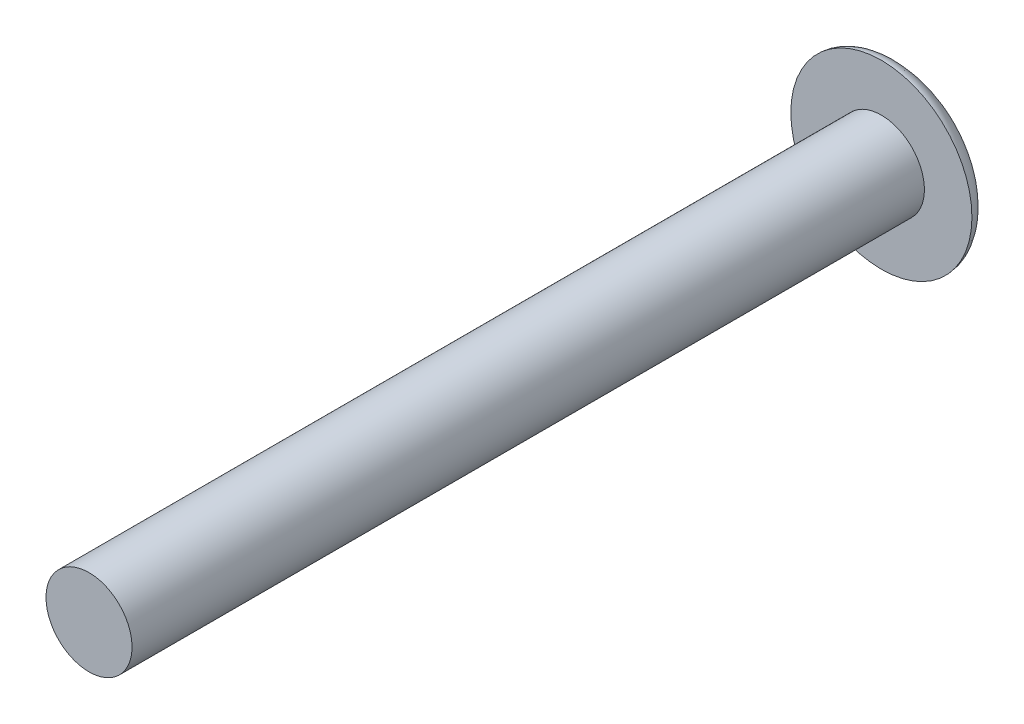
from build123d import *

# Parameters (mm, degrees)
CORTE_EXTRUS_O1_START = -0.5
ESBO_O2_W             = 9.2
ESBO_O2_H             = 1
CORTE_EXTRUS_O1_DEPTH = 10


with BuildPart() as part:
    # Esboço1 → Revolução1 (revolve)
    with BuildSketch(Plane(origin=(0, 0, 0), x_dir=(1, 0, 0), z_dir=(0, 1, 0))):
        with BuildLine():
            Line((1.9, 0), (4, 0))
            add(Edge.make_bspline(
                [(4, 0), (4, 1.5), (0, 1.5)],
                knots=[0, 0, 0, 1.570796327, 1.570796327, 1.570796327], degree=2, weights=[1, 0.707106781, 1]))
            Line((0, 1.5), (0, 0))
            Line((0, 0), (0, -35))
            Line((0, -35), (1.9, -35))
            Line((1.9, -35), (1.9, 0))
        make_face()
    revolve(axis=Axis((0, 0, 0), (0, 0, 1)))

    # Esboço2 → Corte-extrusão1 (cut)
    with BuildSketch(Plane.XY.offset(CORTE_EXTRUS_O1_START)):
        Rectangle(ESBO_O2_W, ESBO_O2_H)
    extrude(amount=-CORTE_EXTRUS_O1_DEPTH, mode=Mode.SUBTRACT)


solid = part.part
